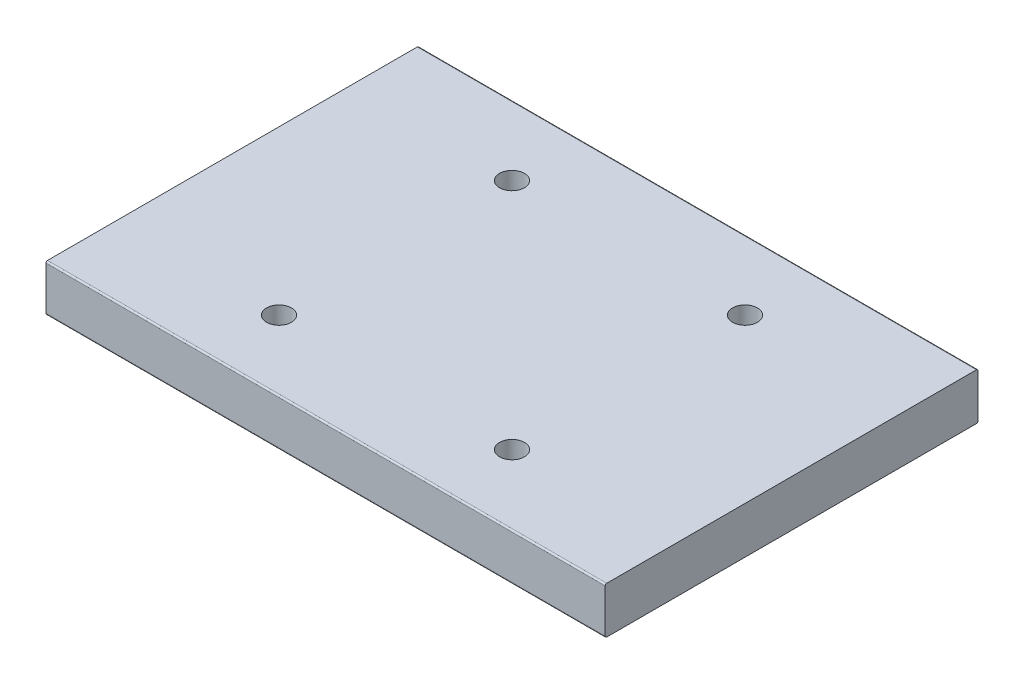
from build123d import *

# Parameters (mm, degrees)
SKETCH3_W                = 152.4
SKETCH3_H                = 101.6
BOSS_EXTRUDE1_DEPTH      = 6.35
BOSS_EXTRUDE1_DEPTH_BACK = 6.35
FILLET1_R                = 0.4191
SKETCH5_R                = 3.4036
CUT_EXTRUDE2_DEPTH       = 13.7


with BuildPart() as part:
    # Sketch3 → Boss-Extrude1 (new body, two sides)
    with BuildSketch(Plane(origin=(0, 0, 0), x_dir=(1, 0, 0), z_dir=(0, 1, 0))) as boss_extrude1_sk:
        Rectangle(SKETCH3_W, SKETCH3_H)
    extrude(amount=BOSS_EXTRUDE1_DEPTH)
    extrude(boss_extrude1_sk.sketch, amount=-BOSS_EXTRUDE1_DEPTH_BACK)

    # Fillet1
    fillet1_edges = [part.edges().sort_by_distance(p)[0] for p in [
        (0, -6.35, -50.8),
        (0, -6.35, 50.8),
        (0, 6.35, -50.8),
        (0, 6.35, 50.8),
    ]]
    fillet(fillet1_edges, radius=FILLET1_R)

    # Sketch5 → Cut-Extrude2 (cut, through all)
    with BuildSketch(Plane(origin=(0, 6.35, 0), x_dir=(1, 0, 0), z_dir=(0, 1, 0))):
        with Locations((31.75, 31.75)):
            Circle(SKETCH5_R)
        with Locations((31.75, -31.75)):
            Circle(SKETCH5_R)
        with Locations((-31.75, -31.75)):
            Circle(SKETCH5_R)
        with Locations((-31.75, 31.75)):
            Circle(SKETCH5_R)
    extrude(amount=-CUT_EXTRUDE2_DEPTH, mode=Mode.SUBTRACT)


solid = part.part
